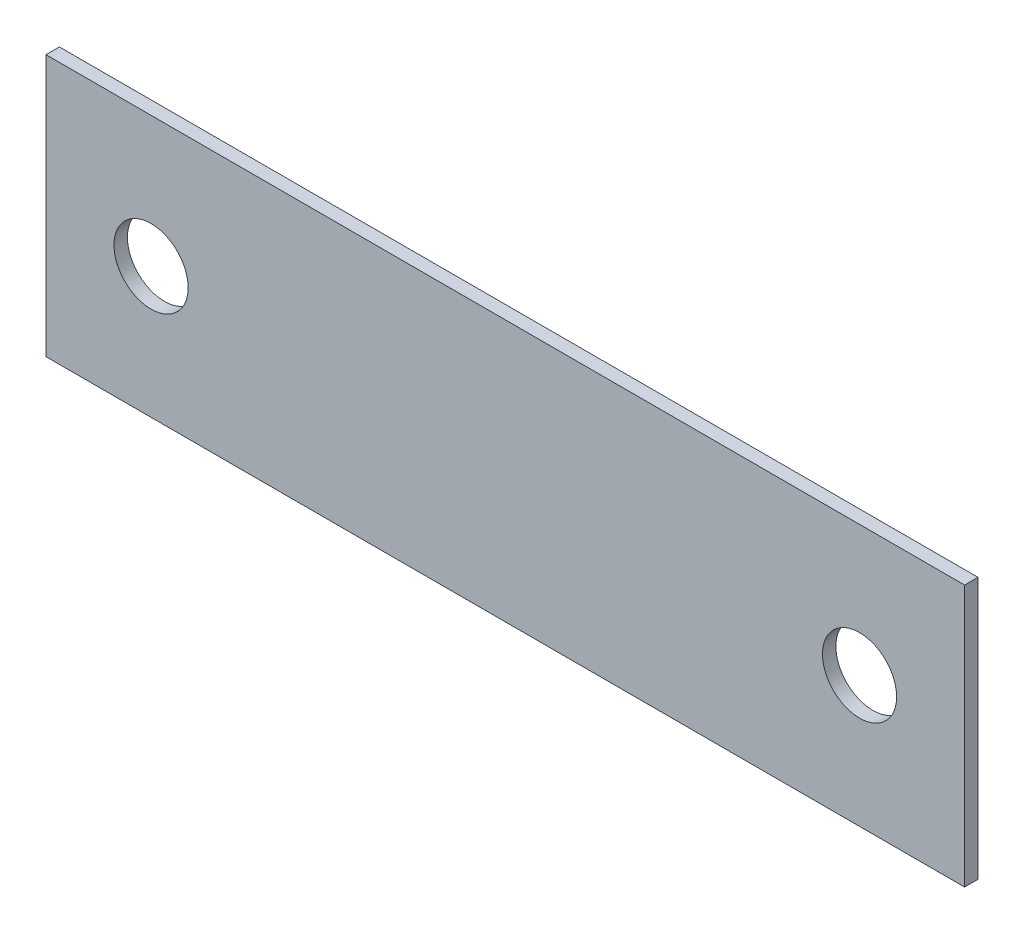
from build123d import *

# Parameters (mm, degrees)
SKETCH2_W            = 55.753
SKETCH2_H            = 15.875
BOSS_EXTRUDE1_DEPTH  = 0.8128
M4_CLEARANCE_HOLE1_D = 4.5


with BuildPart() as part:
    # Sketch2 → Boss-Extrude1 (new body)
    with BuildSketch(Plane.XY):
        with Locations((-2.701977541, 8.999286052)):
            Rectangle(SKETCH2_W, SKETCH2_H)
    extrude(amount=BOSS_EXTRUDE1_DEPTH)

    # M4 Clearance Hole1 (through all)
    with Locations(Plane.XY.offset(0.8128)):
        with Locations((-24.201807541, 8.999286052), (18.797852459, 8.999286052)):
            Hole(M4_CLEARANCE_HOLE1_D / 2)


solid = part.part
